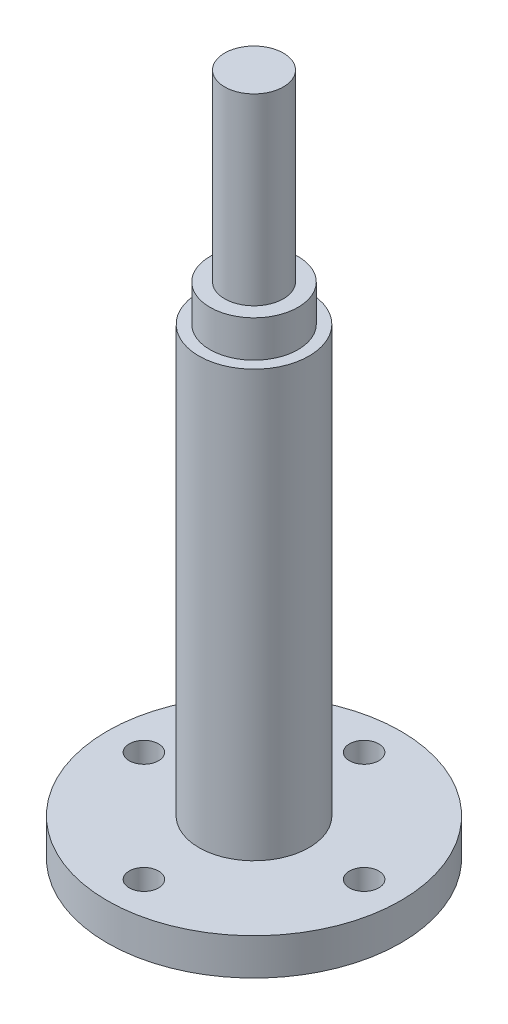
from build123d import *

# Parameters (mm, degrees)
SKETCH1_R           = 20
BOSS_EXTRUDE1_DEPTH = 5
SKETCH2_R           = 7.5
BOSS_EXTRUDE2_DEPTH = 63
SKETCH3_R           = 4
BOSS_EXTRUDE3_DEPTH = 25
SKETCH4_R           = 2
CUT_EXTRUDE1_DEPTH  = 25
SKETCH5_R           = 7.5
SKETCH5_R_2         = 6
CUT_EXTRUDE2_DEPTH  = 5


with BuildPart() as part:
    # Sketch1 → Boss-Extrude1 (new body)
    with BuildSketch(Plane(origin=(0, 0, 0), x_dir=(1, 0, 0), z_dir=(0, 1, 0))):
        Circle(SKETCH1_R)
    extrude(amount=BOSS_EXTRUDE1_DEPTH)

    # Sketch2 → Boss-Extrude2 (add)
    with BuildSketch(Plane(origin=(0, 5, 0), x_dir=(1, 0, 0), z_dir=(0, 1, 0))):
        Circle(SKETCH2_R)
    extrude(amount=BOSS_EXTRUDE2_DEPTH)

    # Sketch3 → Boss-Extrude3 (add)
    with BuildSketch(Plane(origin=(0, 68, 0), x_dir=(1, 0, 0), z_dir=(0, 1, 0))):
        Circle(SKETCH3_R)
    extrude(amount=BOSS_EXTRUDE3_DEPTH)

    # Sketch4 → Cut-Extrude1 (cut)
    with BuildSketch(Plane(origin=(0, 5, 0), x_dir=(1, 0, 0), z_dir=(0, 1, 0))):
        with Locations((0, 15)):
            Circle(SKETCH4_R)
        with Locations((15, 0)):
            Circle(SKETCH4_R)
        with Locations((0, -15)):
            Circle(SKETCH4_R)
        with Locations((-15, 0)):
            Circle(SKETCH4_R)
    extrude(amount=-CUT_EXTRUDE1_DEPTH, mode=Mode.SUBTRACT)

    # Sketch5 → Cut-Extrude2 (cut)
    with BuildSketch(Plane(origin=(0, 68, 0), x_dir=(1, 0, 0), z_dir=(0, 1, 0))):
        Circle(SKETCH5_R)
        Circle(SKETCH5_R_2, mode=Mode.SUBTRACT)
    extrude(amount=-CUT_EXTRUDE2_DEPTH, mode=Mode.SUBTRACT)


solid = part.part
